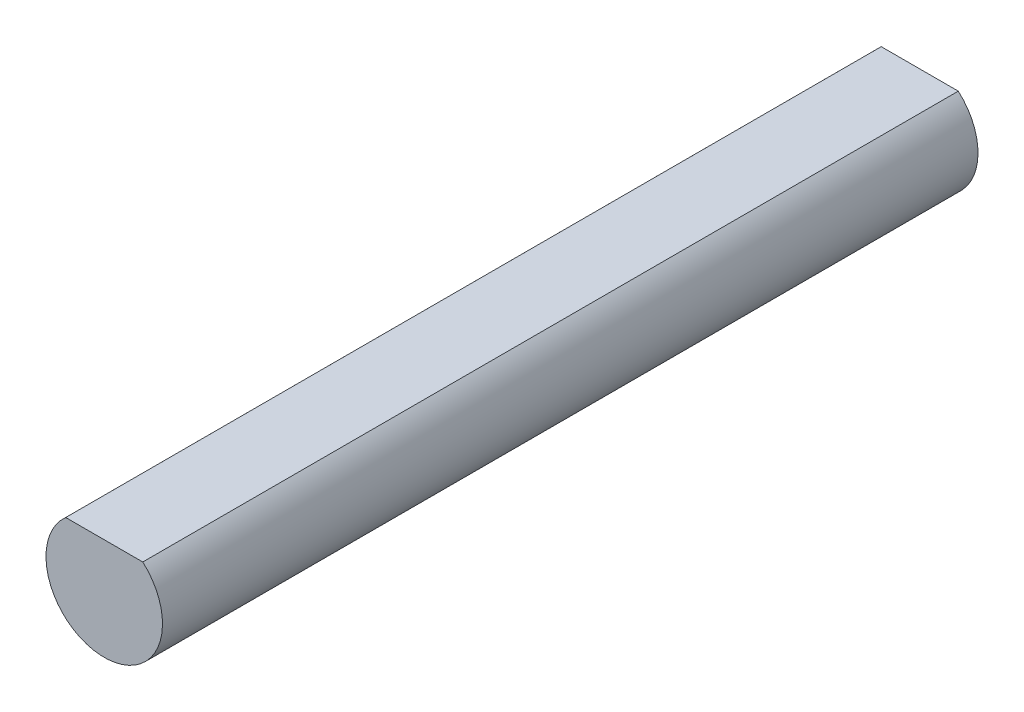
from build123d import *

# Parameters (mm, degrees)
BOSS_EXTRUDE1_DEPTH = 28


with BuildPart() as part:
    # Sketch1 → Boss-Extrude1 (new body)
    with BuildSketch(Plane.XY):
        with BuildLine():
            Line((-1.322875656, 1.5), (1.322875656, 1.5))
            ThreePointArc((1.322875656, 1.5), (0, -2), (-1.322875656, 1.5))
        make_face()
    extrude(amount=BOSS_EXTRUDE1_DEPTH)


solid = part.part
